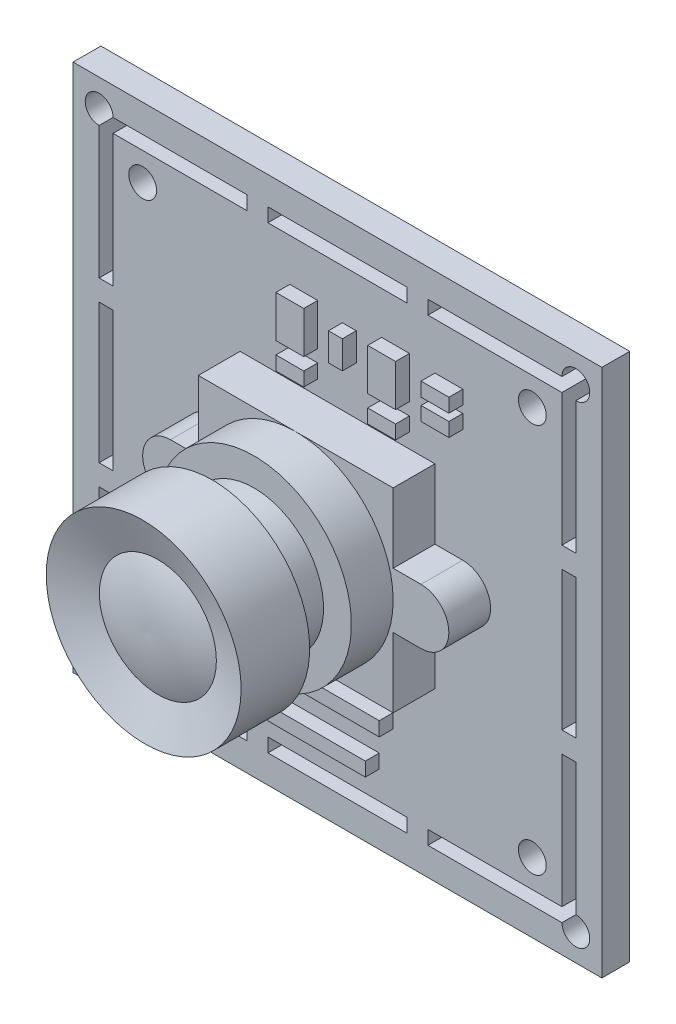
from build123d import *

# Parameters (mm, degrees)
SKETCH_1_W          = 38
SKETCH_1_H          = 38
EXTRUDE_1_DEPTH     = 2
SKETCH_2_W          = 10
SKETCH_2_H          = 0.992079415
SKETCH_2_W_2        = 1
SKETCH_2_H_2        = 10
SKETCH_2_R          = 1
CUT_EXTRUDE_1_DEPTH = 2
SKETCH_3_W          = 14
SKETCH_3_H          = 14
EXTRUDE_2_DEPTH     = 3
SKETCH_6_W          = 3
SKETCH_6_H          = 5
SKETCH_6_W_2        = 5
SKETCH_6_H_2        = 3
SKETCH_6_W_3        = 2
SKETCH_6_W_4        = 1
SKETCH_6_H_3        = 2
SKETCH_6_H_4        = 1
SKETCH_6_W_5        = 0.5
SKETCH_6_W_6        = 9
SKETCH_6_H_5        = 1.013833389
SKETCH_6_W_7        = 7
EXTRUDE_3_DEPTH     = 1
SKETCH_7_W          = 9.5
SKETCH_7_H          = 5
SKETCH_7_W_2        = 8.9
SKETCH_7_H_2        = 4.4
SKETCH_7_R          = 0.125
EXTRUDE_6_DEPTH     = 6
SKETCH_8_R          = 1.591054527
SKETCH_8_R_2        = 1.538344003
SKETCH_8_W          = 5.694239319
SKETCH_8_H          = 5.388097421
SKETCH_8_W_2        = 4.592128484
SKETCH_8_H_2        = 3.857387926
SKETCH_8_W_3        = 1.163339215
SKETCH_8_H_3        = 0.551055418
SKETCH_8_H_4        = 0.489827039
SKETCH_8_W_4        = 0.581669607
SKETCH_8_H_5        = 0.612283798
SKETCH_8_W_5        = 1.653166254
SKETCH_8_H_6        = 2.449135191
SKETCH_8_W_6        = 1.224567596
SKETCH_8_H_7        = 2.142993292
SKETCH_8_W_7        = 2.020536533
SKETCH_8_W_8        = 2.87773385
SKETCH_8_H_8        = 0.979654077
SKETCH_8_W_9        = 1.836851394
SKETCH_8_H_9        = 0.918425696
SKETCH_8_W_10       = 1.836851393
SKETCH_8_H_10       = 1.224567595
SKETCH_8_H_11       = 0.24491352
SKETCH_8_W_11       = 0.612283797
SKETCH_8_H_12       = 2.326678432
SKETCH_8_W_12       = 1.347024355
SKETCH_8_H_13       = 0.428598658
SKETCH_8_H_14       = 0.734740557
SKETCH_8_W_13       = 0.489827038
SKETCH_8_H_15       = 1.898079773
SKETCH_8_W_14       = 0.918425697
SKETCH_8_H_16       = 0.367370279
SKETCH_8_H_17       = 0.367370278
EXTRUDE_5_DEPTH     = 1


with BuildPart() as part:
    # 草图1 → 凸台-拉伸1 (new body)
    with BuildSketch(Plane.XY):
        Rectangle(SKETCH_1_W, SKETCH_1_H)
    extrude(amount=EXTRUDE_1_DEPTH)

    # 草图2 → 切除-拉伸1 (cut)
    with BuildSketch(Plane.XY.offset(2)):
        with Locations((0, 16.496039708)):
            Rectangle(SKETCH_2_W, SKETCH_2_H)
        with BuildLine():
            Line((-6.5, 16), (-6.5, 16.992079415))
            Line((-6.5, 16.992079415), (-16.127741149, 16.992079415))
            ThreePointArc((-16.127741149, 16.992079415), (-17.834847931, 17.699186196), (-17.127741149, 15.992079415))
            Line((-17.127741149, 15.992079415), (-17.127741149, 6.5))
            Line((-17.127741149, 6.5), (-16.127741149, 6.5))
            Line((-16.127741149, 6.5), (-16.127741149, 16))
            Line((-16.127741149, 16), (-6.5, 16))
        make_face()
        with BuildLine():
            Line((16.127741149, 16.992079415), (6.5, 16.992079415))
            Line((6.5, 16.992079415), (6.5, 16))
            Line((6.5, 16), (16.127741149, 16))
            Line((16.127741149, 16), (16.127741149, 6.5))
            Line((16.127741149, 6.5), (17.127741149, 6.5))
            Line((17.127741149, 6.5), (17.127741149, 15.992079415))
            ThreePointArc((17.127741149, 15.992079415), (17.834847931, 17.699186196), (16.127741149, 16.992079415))
        make_face()
        with Locations((-16.627741149, 0)):
            Rectangle(SKETCH_2_W_2, SKETCH_2_H_2)
        with Locations((16.627741149, 0)):
            Rectangle(SKETCH_2_W_2, SKETCH_2_H_2)
        with BuildLine():
            Line((-16.127741149, -16), (-16.127741149, -6.5))
            Line((-16.127741149, -6.5), (-17.127741149, -6.5))
            Line((-17.127741149, -6.5), (-17.127741149, -15.992079415))
            ThreePointArc((-17.127741149, -15.992079415), (-17.834847931, -17.699186196), (-16.127741149, -16.992079415))
            Line((-16.127741149, -16.992079415), (-6.5, -16.992079415))
            Line((-6.5, -16.992079415), (-6.5, -16))
            Line((-6.5, -16), (-16.127741149, -16))
        make_face()
        with BuildLine():
            Line((17.127741149, -6.5), (16.127741149, -6.5))
            Line((16.127741149, -6.5), (16.127741149, -16))
            Line((16.127741149, -16), (6.5, -16))
            Line((6.5, -16), (6.5, -16.992079415))
            Line((6.5, -16.992079415), (16.127741149, -16.992079415))
            ThreePointArc((16.127741149, -16.992079415), (17.834847931, -17.699186196), (17.127741149, -15.992079415))
            Line((17.127741149, -15.992079415), (17.127741149, -6.5))
        make_face()
        with Locations((0, -16.496039708)):
            Rectangle(SKETCH_2_W, SKETCH_2_H)
        with Locations((-14, 14)):
            Circle(SKETCH_2_R)
        with Locations((14, 14)):
            Circle(SKETCH_2_R)
        with Locations((-14, -14)):
            Circle(SKETCH_2_R)
        with Locations((14, -14)):
            Circle(SKETCH_2_R)
    extrude(amount=-CUT_EXTRUDE_1_DEPTH, mode=Mode.SUBTRACT)

    # 草图3 → 凸台-拉伸2 (add)
    with BuildSketch(Plane.XY.offset(2)):
        Rectangle(SKETCH_3_W, SKETCH_3_H)
        with BuildLine():
            Line((-9, 2), (9, 2))
            ThreePointArc((9, 2), (11, 0), (9, -2))
            Line((9, -2), (-9, -2))
            ThreePointArc((-9, -2), (-11, 0), (-9, 2))
        make_face()
    extrude(amount=EXTRUDE_2_DEPTH)

    # 草图4 → 旋转1 (revolve)
    with BuildSketch(Plane(origin=(0, 0, 0), x_dir=(0, 0, -1), z_dir=(1, 0, 0))):
        Polygon((-5, 0), (-16, 0), (-16, 7), (-11, 7), (-11, 5), (-8, 5), (-8, 7), (-5, 7), align=None)
    revolve(axis=Axis((0, 0, 5), (0, 0, 1)))

    # 草图5 → 切除-旋转2 (revolve, cut)
    with BuildSketch(Plane(origin=(0, 0, 0), x_dir=(0, 0, -1), z_dir=(1, 0, 0))):
        with BuildLine():
            Line((-16, 7), (-14.908089297, 4))
            ThreePointArc((-14.908089297, 4), (-15.509784856, 1.938266045), (-15.657356852, -0.204397473))
            Line((-15.657356852, -0.204397473), (-16, -0.204397473))
            Line((-16, -0.204397473), (-16, 7))
        make_face()
    revolve(axis=Axis((0, -0.204397473, 16), (0, 0, -1)), mode=Mode.SUBTRACT)

    # 草图6 → 凸台-拉伸3 (add)
    with BuildSketch(Plane.XY.offset(2)):
        with Locations((-12.5, -8.5)):
            Rectangle(SKETCH_6_W, SKETCH_6_H)
        with Locations((-9.5, -13.5)):
            Rectangle(SKETCH_6_W_2, SKETCH_6_H_2)
        with Locations((-2.424334782, 11.45385229)):
            Rectangle(SKETCH_6_W_3, SKETCH_6_H_2)
        with Locations((0.848936353, 11.45385229)):
            Rectangle(SKETCH_6_W_4, SKETCH_6_H_3)
        with Locations((4.171553284, 11.45385229)):
            Rectangle(SKETCH_6_W_3, SKETCH_6_H_2)
        with Locations((8.004076774, 12.148319115)):
            Rectangle(SKETCH_6_W_3, SKETCH_6_H_4)
        with Locations((8.004076774, 10.635048037)):
            Rectangle(SKETCH_6_W_3, SKETCH_6_H_4)
        with Locations((-2.424334782, 8.563279614)):
            Rectangle(SKETCH_6_W_3, SKETCH_6_H_4)
        with Locations((4.171553284, 8.563279614)):
            Rectangle(SKETCH_6_W_3, SKETCH_6_H_4)
        with Locations((-9.75, -9.5)):
            Rectangle(SKETCH_6_W_5, SKETCH_6_H_3)
        with Locations((-8.25, -9.5)):
            Rectangle(SKETCH_6_W_5, SKETCH_6_H_3)
        with Locations((-0.5, -10.493083306)):
            Rectangle(SKETCH_6_W_6, SKETCH_6_H_5)
        with Locations((-0.5, -13.5)):
            Rectangle(SKETCH_6_W_7, SKETCH_6_H_4)
    extrude(amount=EXTRUDE_3_DEPTH)

    # 草图7 → 6 (add)
    with BuildSketch(Plane(origin=(0, 0, 0), x_dir=(-1, 0, 0), z_dir=(0, 0, -1))):
        with Locations((0, -13.5)):
            Rectangle(SKETCH_7_W, SKETCH_7_H)
        with Locations((0, -13.5)):
            Rectangle(SKETCH_7_W_2, SKETCH_7_H_2, mode=Mode.SUBTRACT)
        with Locations((0.95, -12.7)):
            Circle(SKETCH_7_R)
        with Locations((2.85, -12.7)):
            Circle(SKETCH_7_R)
        with Locations((-2.85, -12.7)):
            Circle(SKETCH_7_R)
        with Locations((-0.95, -12.7)):
            Circle(SKETCH_7_R)
    extrude(amount=EXTRUDE_6_DEPTH)

    # 草图8 → 凸台-拉伸5 (add)
    with BuildSketch(Plane(origin=(0, 0, 0), x_dir=(-1, 0, 0), z_dir=(0, 0, -1))):
        with Locations((-9.306713726, 0)):
            Circle(SKETCH_8_R)
        with Locations((7.347405573, 0)):
            Circle(SKETCH_8_R_2)
        with Locations((7.071877865, -5.296254851)):
            Rectangle(SKETCH_8_W, SKETCH_8_H)
        with Locations((10.072068473, 8.26583127)):
            Rectangle(SKETCH_8_W_2, SKETCH_8_H_2)
        with Locations((12.949802323, -2.326678431)):
            Rectangle(SKETCH_8_W_3, SKETCH_8_H_3)
        with Locations((12.949802323, -3.704316977)):
            Rectangle(SKETCH_8_W_3, SKETCH_8_H_4)
        with Locations((12.949802323, -5.020727142)):
            Rectangle(SKETCH_8_W_3, SKETCH_8_H_3)
        with Locations((13.240637127, -6.459594066)):
            Rectangle(SKETCH_8_W_4, SKETCH_8_H_5)
        with Locations((11.541549588, -10.990494169)):
            Rectangle(SKETCH_8_W_5, SKETCH_8_H_6)
        with Locations((14.143755728, -10.470052942)):
            Rectangle(SKETCH_8_W_6, SKETCH_8_H_7)
        with Locations((-8.296445459, -10.470052942)):
            Rectangle(SKETCH_8_W_7, SKETCH_8_H_7)
        with Locations((-8.725044118, -6.949421105)):
            Rectangle(SKETCH_8_W_8, SKETCH_8_H_8)
        with Locations((-4.102301445, -8.449516409)):
            Rectangle(SKETCH_8_W_9, SKETCH_8_H_9)
        with Locations((-4.469671724, -1.989922343)):
            Rectangle(SKETCH_8_W_10, SKETCH_8_H_10)
        with Locations((-4.469671724, -3.826773736)):
            Rectangle(SKETCH_8_W_10, SKETCH_8_H_11)
        with Locations((-10.470052942, 11.970148246)):
            Rectangle(SKETCH_8_W_11, SKETCH_8_H_12)
        with Locations((-7.959689371, 12.551817854)):
            Rectangle(SKETCH_8_W_12, SKETCH_8_H_13)
        with Locations((-7.959689371, 11.602777967)):
            Rectangle(SKETCH_8_W_12, SKETCH_8_H_14)
        with Locations((-5.633010939, 12.184447576)):
            Rectangle(SKETCH_8_W_13, SKETCH_8_H_15)
        with Locations((-3.643088597, 12.368132714)):
            Rectangle(SKETCH_8_W_14, SKETCH_8_H_16)
        with Locations((-3.643088597, 11.419092828)):
            Rectangle(SKETCH_8_W_14, SKETCH_8_H_17)
    extrude(amount=EXTRUDE_5_DEPTH)


solid = part.part
